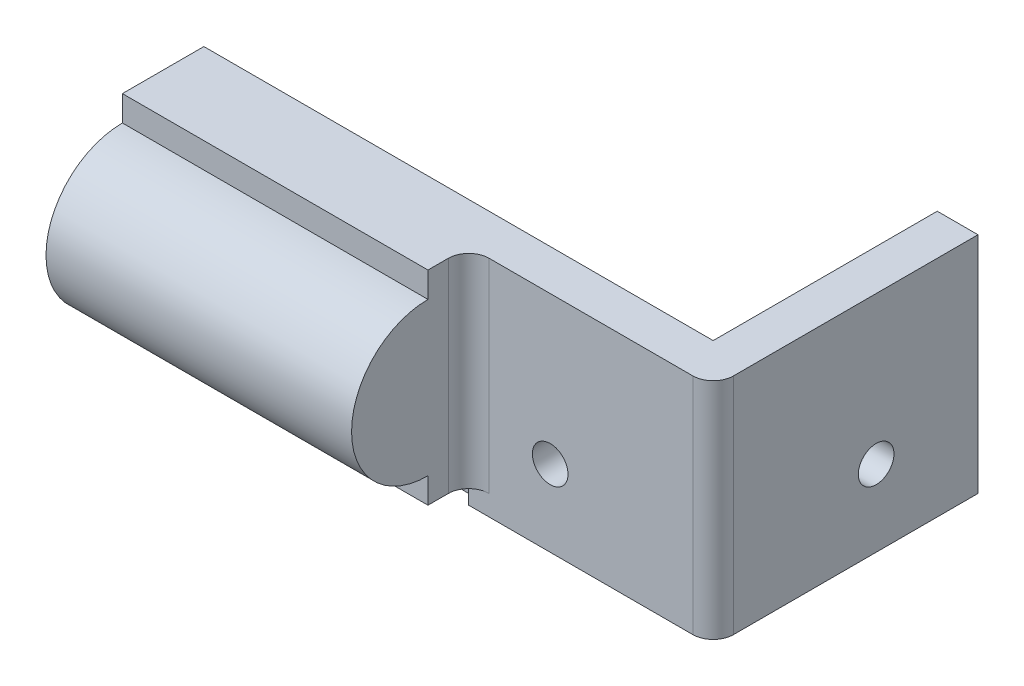
from build123d import *

# Parameters (mm, degrees)
SKETCH1_W           = 50
SKETCH1_H           = 30
BOSS_EXTRUDE1_DEPTH = 3
SKETCH2_R           = 1.75
CUT_EXTRUDE1_DEPTH  = 4
SKETCH3_W           = 30
SKETCH3_H           = 20
BOSS_EXTRUDE2_DEPTH = 5
BOSS_EXTRUDE3_DEPTH = 30
SKETCH5_R           = 4
CUT_EXTRUDE2_DEPTH  = 20
SKETCH6_W           = 50
SKETCH6_H           = 8
CUT_EXTRUDE3_DEPTH  = 20
SKETCH7_W           = 3
SKETCH7_H           = 22
BOSS_EXTRUDE4_DEPTH = 3
SKETCH8_W           = 3
SKETCH8_H           = 22
BOSS_EXTRUDE5_DEPTH = 22
SKETCH9_R           = 1.75
CUT_EXTRUDE4_DEPTH  = 54
SKETCH10_W          = 23
SKETCH10_H          = 22
SKETCH10_R          = 1.75
BOSS_EXTRUDE6_DEPTH = 1
SKETCH11_W          = 26
SKETCH11_H          = 22
SKETCH11_R          = 1.75
BOSS_EXTRUDE7_DEPTH = 1
FILLET1_R           = 2


with BuildPart() as part:
    # Sketch1 → Boss-Extrude1 (new body)
    with BuildSketch(Plane.XY):
        with Locations((25, 15)):
            Rectangle(SKETCH1_W, SKETCH1_H)
    extrude(amount=BOSS_EXTRUDE1_DEPTH)

    # Sketch2 → Cut-Extrude1 (cut, through all)
    with BuildSketch(Plane.XY.offset(3)):
        with Locations((38, 7.5)):
            Circle(SKETCH2_R)
    extrude(amount=-CUT_EXTRUDE1_DEPTH, mode=Mode.SUBTRACT)

    # Sketch3 → Boss-Extrude2 (add)
    with BuildSketch(Plane.XY.offset(3)):
        with Locations((15, 12)):
            Rectangle(SKETCH3_W, SKETCH3_H)
    extrude(amount=BOSS_EXTRUDE2_DEPTH)

    # Sketch4 → Boss-Extrude3 (add)
    with BuildSketch(Plane.ZY):
        with BuildLine():
            Line((8, 4.5), (8, 19.5))
            ThreePointArc((8, 19.5), (15.5, 12), (8, 4.5))
        make_face()
    extrude(amount=-BOSS_EXTRUDE3_DEPTH)

    # Sketch5 → Cut-Extrude2 (cut)
    with BuildSketch(Plane.ZY):
        with Locations((8, 12)):
            Circle(SKETCH5_R)
    extrude(amount=-CUT_EXTRUDE2_DEPTH, mode=Mode.SUBTRACT)

    # Sketch6 → Cut-Extrude3 (cut)
    with BuildSketch(Plane.XY.offset(3)):
        with Locations((25, 26)):
            Rectangle(SKETCH6_W, SKETCH6_H)
    extrude(amount=-CUT_EXTRUDE3_DEPTH, mode=Mode.SUBTRACT)

    # Sketch7 → Boss-Extrude4 (add)
    with BuildSketch(Plane(origin=(50, 0, 0), x_dir=(0, 0, -1), z_dir=(1, 0, 0))):
        with Locations((-1.5, 11)):
            Rectangle(SKETCH7_W, SKETCH7_H)
    extrude(amount=BOSS_EXTRUDE4_DEPTH)

    # Sketch8 → Boss-Extrude5 (add)
    with BuildSketch(Plane(origin=(0, 0, 0), x_dir=(-1, 0, 0), z_dir=(0, 0, -1))):
        with Locations((-51.5, 11)):
            Rectangle(SKETCH8_W, SKETCH8_H)
    extrude(amount=BOSS_EXTRUDE5_DEPTH)

    # Sketch9 → Cut-Extrude4 (cut, through all)
    with BuildSketch(Plane(origin=(53, 0, 0), x_dir=(0, 0, -1), z_dir=(1, 0, 0))):
        with Locations((12, 7.5)):
            Circle(SKETCH9_R)
    extrude(amount=-CUT_EXTRUDE4_DEPTH, mode=Mode.SUBTRACT)

    # Sketch10 → Boss-Extrude6 (add)
    with BuildSketch(Plane.XY.offset(3)):
        with Locations((41.5, 11)):
            Rectangle(SKETCH10_W, SKETCH10_H)
        with Locations((38, 7.5)):
            Circle(SKETCH10_R, mode=Mode.SUBTRACT)
    extrude(amount=BOSS_EXTRUDE6_DEPTH)

    # Sketch11 → Boss-Extrude7 (add)
    with BuildSketch(Plane(origin=(53, 0, 0), x_dir=(0, 0, -1), z_dir=(1, 0, 0))):
        with Locations((9, 11)):
            Rectangle(SKETCH11_W, SKETCH11_H)
        with Locations((12, 7.5)):
            Circle(SKETCH11_R, mode=Mode.SUBTRACT)
    extrude(amount=BOSS_EXTRUDE7_DEPTH)

    # Fillet1
    fillet1_edges = [part.edges().sort_by_distance(p)[0] for p in [
        (30, 12, 4),
        (54, 11, 4),
    ]]
    fillet(fillet1_edges, radius=FILLET1_R)


solid = part.part
